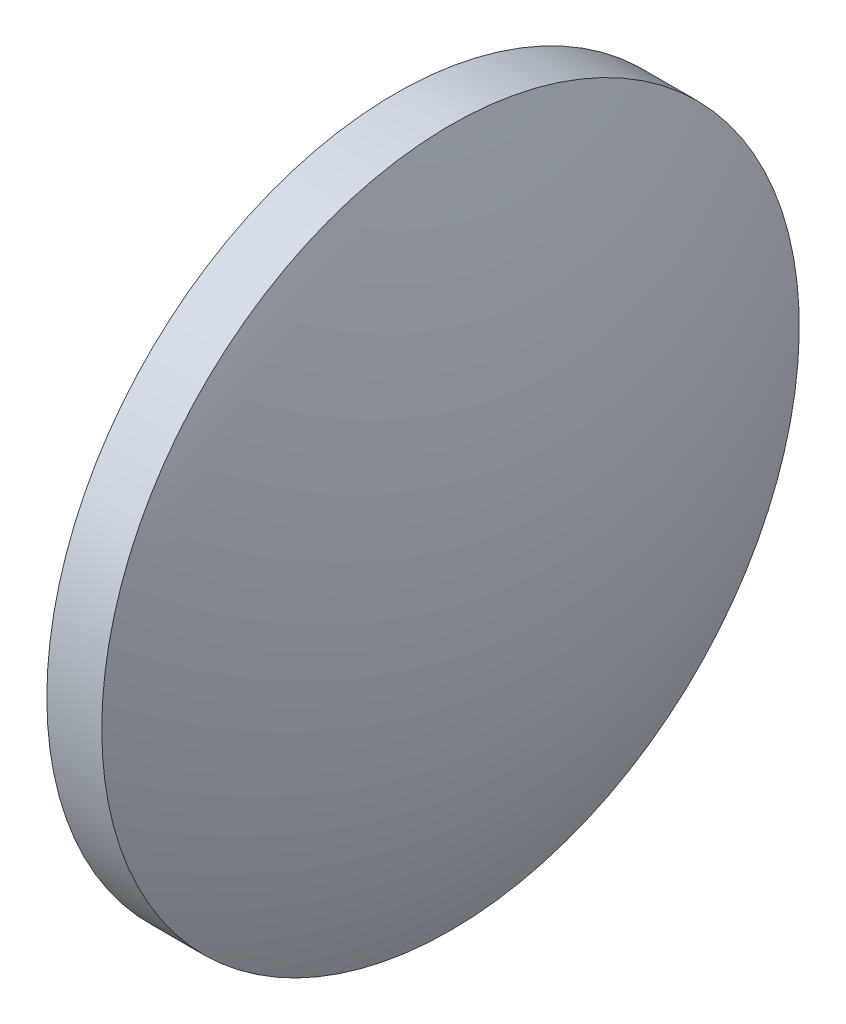
from build123d import *


with BuildPart() as part:
    # 草图1 → 旋转1 (revolve)
    with BuildSketch(Plane.XY, mode=Mode.PRIVATE) as revolve_1_sk:
        with BuildLine():
            Line((435.045141601, 143.14773479), (435.045141601, 155.84773479))
            Line((435.045141601, 155.84773479), (437.045141601, 155.84773479))
            ThreePointArc((437.045141601, 155.84773479), (438.988469981, 149.629439813), (439.645141601, 143.14773479))
            Line((439.645141601, 143.14773479), (435.045141601, 143.14773479))
        make_face()
    revolve(revolve_1_sk.sketch.rotate(Axis((429.306923565, 143.14773479, 0), (1, 0, 0)), 180), axis=Axis((429.306923565, 143.14773479, 0), (1, 0, 0)))  # turned: the seam where the file's is


solid = part.part
